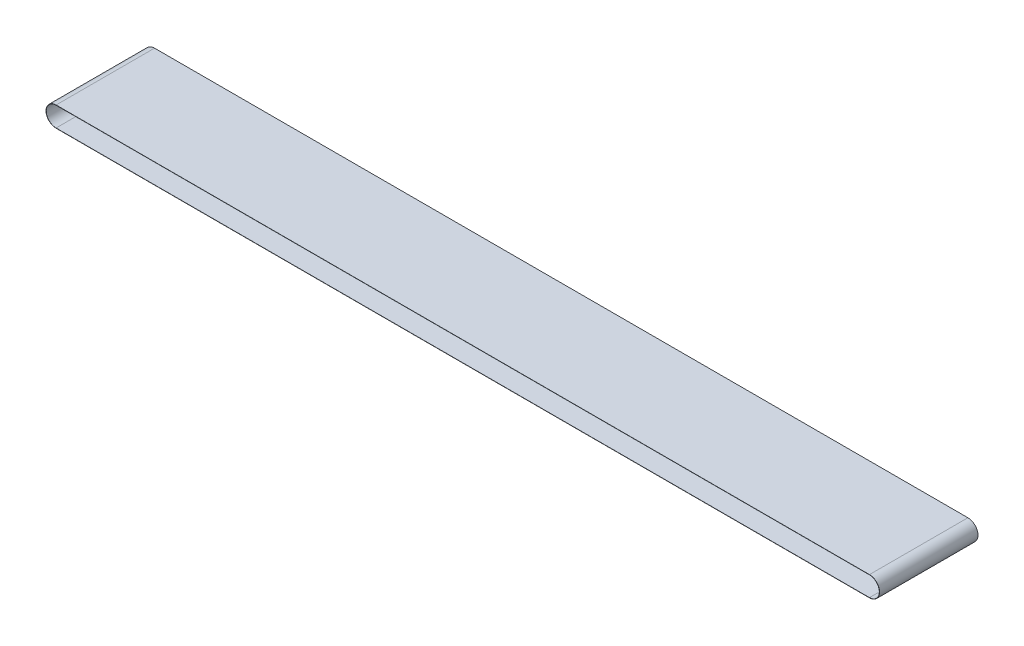
from build123d import *

# Parameters (mm, degrees)
BOSS_EXTRUDE1_DEPTH = 250


with BuildPart() as part:
    # Sketch1 → Boss-Extrude1 (new body, symmetric)
    with BuildSketch(Plane.XY):
        with BuildLine():
            Line((0, -51.2), (4130.96, -51.2))
            ThreePointArc((4130.96, -51.2), (4182.16, 0), (4130.96, 51.2))
            Line((4130.96, 51.2), (0, 51.2))
            ThreePointArc((0, 51.2), (-51.2, 0), (0, -51.2))
        make_face()
        with BuildLine():
            Line((0, 50), (4130.96, 50))
            ThreePointArc((4130.96, 50), (4180.96, 0), (4130.96, -50))
            Line((4130.96, -50), (0, -50))
            ThreePointArc((0, -50), (-50, 0), (0, 50))
        make_face(mode=Mode.SUBTRACT)
    extrude(amount=BOSS_EXTRUDE1_DEPTH, both=True)


solid = part.part
